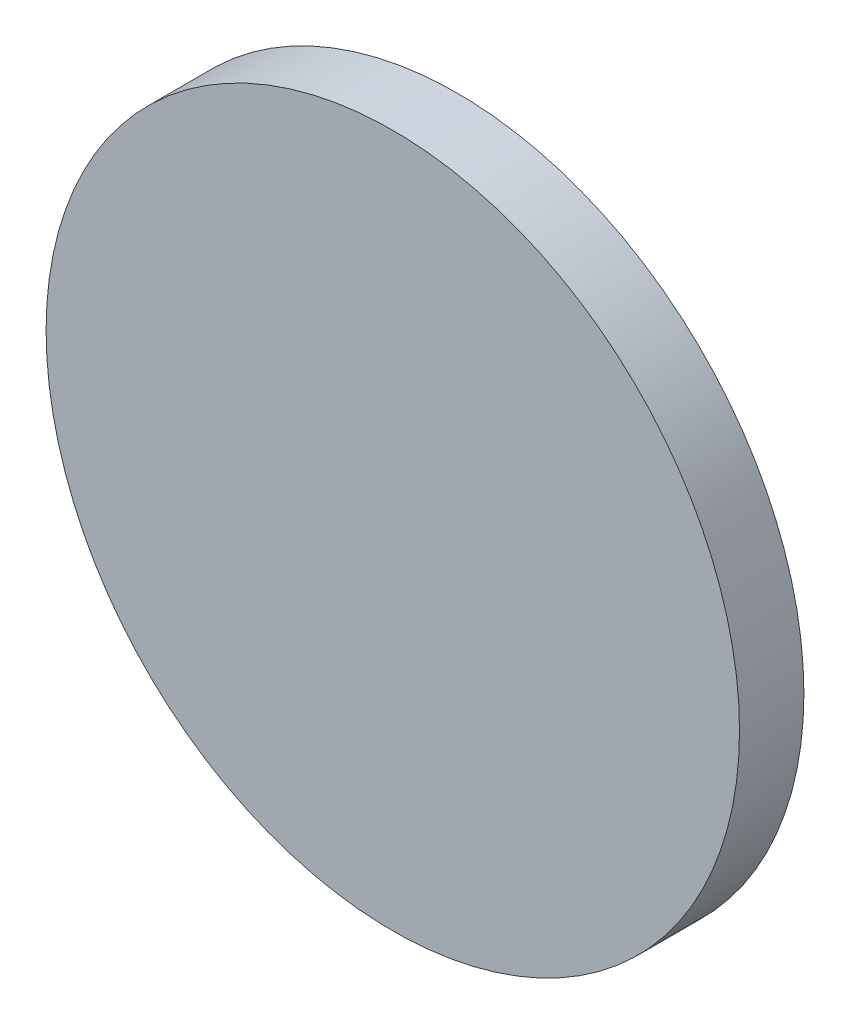
from build123d import *

# Parameters (mm, degrees)
SKIZZE1_R                       = 35
AUFSATZ_LINEAR_AUSTRAGEN1_DEPTH = 6.5


with BuildPart() as part:
    # Skizze1 → Aufsatz-Linear austragen1 (new body)
    with BuildSketch(Plane.XY):
        Circle(SKIZZE1_R)
    extrude(amount=AUFSATZ_LINEAR_AUSTRAGEN1_DEPTH)


solid = part.part
